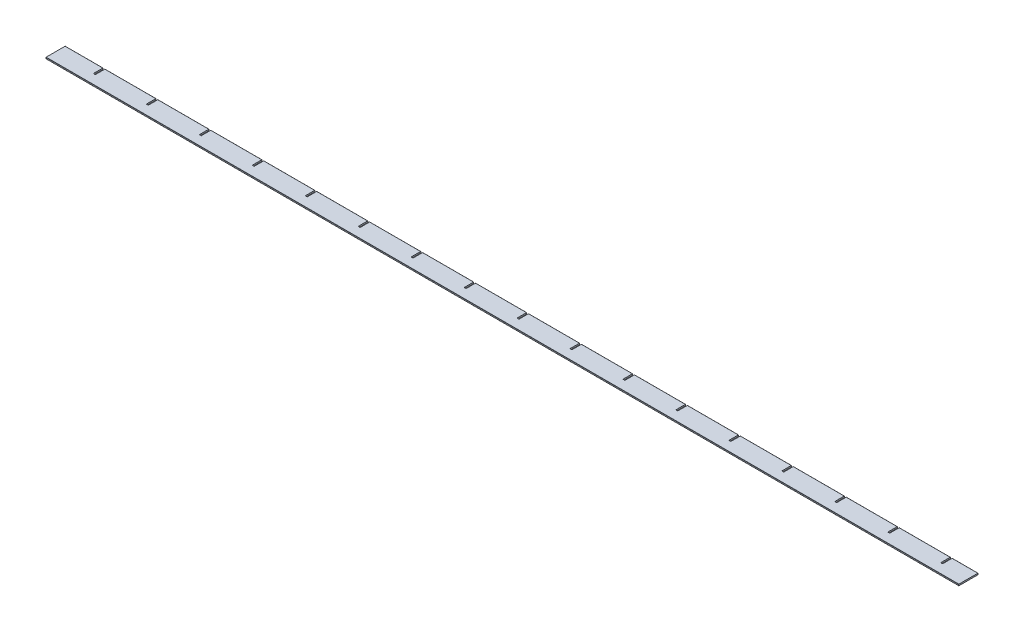
from build123d import *

# Parameters (mm, degrees)
SKETCH1_W                = 1896
SKETCH1_H                = 40
BOSS_EXTRUDE1_DEPTH      = 1.5
BOSS_EXTRUDE1_DEPTH_BACK = 1.5
FILLET1_R                = 0.35
SKETCH2_W                = 4
SKETCH2_H                = 20
CUT_EXTRUDE1_DEPTH       = 4


with BuildPart() as part:
    # Sketch1 → Boss-Extrude1 (new body, two sides)
    with BuildSketch(Plane(origin=(0, 0, 0), x_dir=(1, 0, 0), z_dir=(0, 1, 0))) as boss_extrude1_sk:
        Rectangle(SKETCH1_W, SKETCH1_H)
    extrude(amount=BOSS_EXTRUDE1_DEPTH)
    extrude(boss_extrude1_sk.sketch, amount=-BOSS_EXTRUDE1_DEPTH_BACK)

    # Fillet1
    fillet1_edges = [part.edges().sort_by_distance(p)[0] for p in [
        (0, 1.5, -20),
        (0, 1.5, 20),
        (0, -1.5, 20),
        (0, -1.5, -20),
    ]]
    fillet(fillet1_edges, radius=FILLET1_R)

    # Sketch2 → Cut-Extrude1 (cut, through all)
    with BuildSketch(Plane(origin=(0, 1.5, 0), x_dir=(1, 0, 0), z_dir=(0, 1, 0))):
        with Locations((782.51, 10)):
            Rectangle(SKETCH2_W, SKETCH2_H)
        with Locations((892.51, 10)):
            Rectangle(SKETCH2_W, SKETCH2_H)
        with Locations((672.51, 10)):
            Rectangle(SKETCH2_W, SKETCH2_H)
        with Locations((562.51, 10)):
            Rectangle(SKETCH2_W, SKETCH2_H)
        with Locations((452.51, 10)):
            Rectangle(SKETCH2_W, SKETCH2_H)
        with Locations((342.51, 10)):
            Rectangle(SKETCH2_W, SKETCH2_H)
        with Locations((232.51, 10)):
            Rectangle(SKETCH2_W, SKETCH2_H)
        with Locations((122.51, 10)):
            Rectangle(SKETCH2_W, SKETCH2_H)
        with Locations((12.51, 10)):
            Rectangle(SKETCH2_W, SKETCH2_H)
        with Locations((-97.49, 10)):
            Rectangle(SKETCH2_W, SKETCH2_H)
        with Locations((-207.49, 10)):
            Rectangle(SKETCH2_W, SKETCH2_H)
        with Locations((-317.49, 10)):
            Rectangle(SKETCH2_W, SKETCH2_H)
        with Locations((-427.49, 10)):
            Rectangle(SKETCH2_W, SKETCH2_H)
        with Locations((-537.49, 10)):
            Rectangle(SKETCH2_W, SKETCH2_H)
        with Locations((-647.49, 10)):
            Rectangle(SKETCH2_W, SKETCH2_H)
        with Locations((-757.49, 10)):
            Rectangle(SKETCH2_W, SKETCH2_H)
        with Locations((-867.49, 10)):
            Rectangle(SKETCH2_W, SKETCH2_H)
    extrude(amount=-CUT_EXTRUDE1_DEPTH, mode=Mode.SUBTRACT)


solid = part.part
